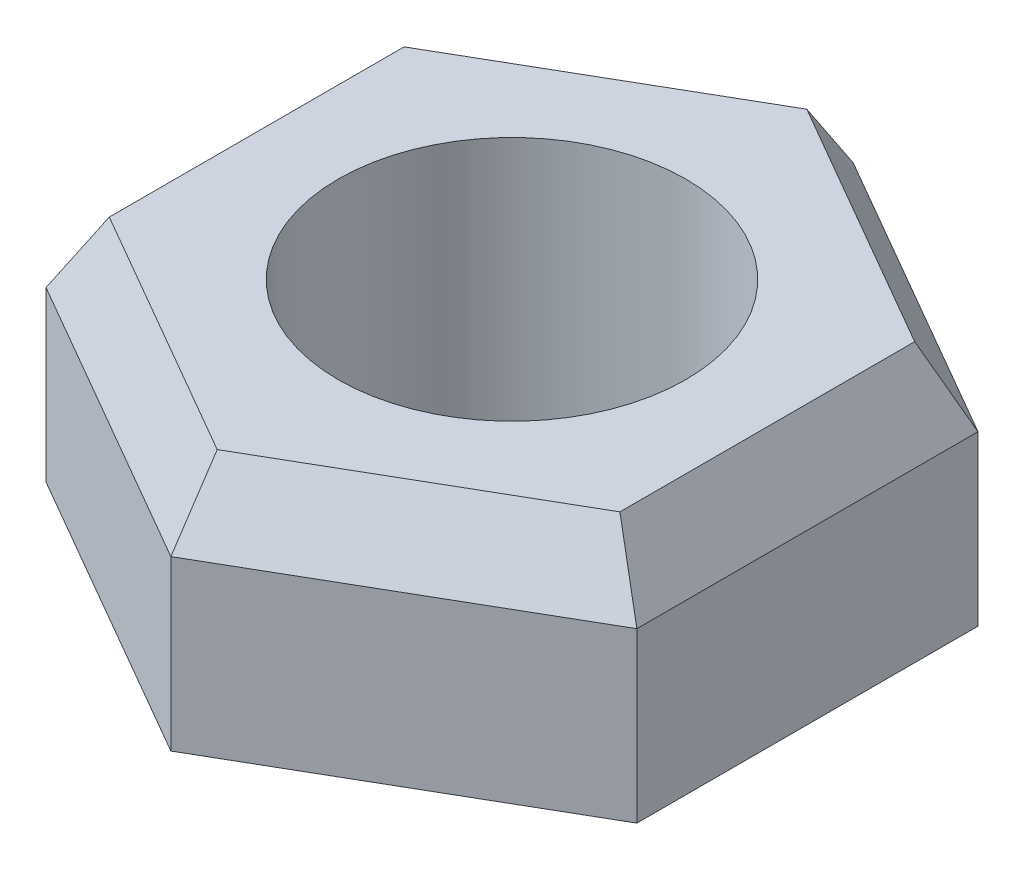
from build123d import *

# Parameters (mm, degrees)
SKETCH_1_R             = 5
EXTRUDE_1_DEPTH        = 8
CHAMFER_1_SIZE         = 2
CHAMFER_1_SIZE2        = 1.154700538
CHAMFER_1_PART_2_SIZE  = 2
CHAMFER_1_PART_2_SIZE2 = 1.154700538
CHAMFER_1_PART_3_SIZE  = 2
CHAMFER_1_PART_3_SIZE2 = 1.154700538
CHAMFER_1_PART_4_SIZE  = 2
CHAMFER_1_PART_4_SIZE2 = 1.154700538
CHAMFER_1_PART_5_SIZE  = 2
CHAMFER_1_PART_5_SIZE2 = 1.154700538
CHAMFER_1_PART_6_SIZE  = 2
CHAMFER_1_PART_6_SIZE2 = 1.154700538
CHAMFER_1_PART_7_SIZE  = 2
CHAMFER_1_PART_7_SIZE2 = 1.154700538


with BuildPart() as part:
    # Эскиз1 → Бобышка-Вытянуть1 (new body)
    with BuildSketch(Plane(origin=(0, 0, 0), x_dir=(1, 0, 0), z_dir=(0, 1, 0))):
        Polygon((8.5, -4.907477288), (8.5, 4.907477288), (0, 9.814954576), (-8.5, 4.907477288), (-8.5, -4.907477288), (0, -9.814954576), align=None)
        Circle(SKETCH_1_R, mode=Mode.SUBTRACT)
    extrude(amount=EXTRUDE_1_DEPTH)

    # Фаска1
    chamfer_1_edges = [part.edges().sort_by_distance(p)[0] for p in [
        (4.25, 8, -7.361215932),
    ]]
    chamfer_1_side = [part.faces().sort_by_distance(p)[0] for p in [
        (4.25, 4, -7.361215932),
    ]]
    chamfer(chamfer_1_edges, length=CHAMFER_1_SIZE, length2=CHAMFER_1_SIZE2, reference=chamfer_1_side[0])

    # Фаска1 part 2
    chamfer_1_part_2_edges = [part.edges().sort_by_distance(p)[0] for p in [
        (-4.25, 8, -7.361215932),
    ]]
    chamfer_1_part_2_side = [part.faces().sort_by_distance(p)[0] for p in [
        (-4.25, 4, -7.361215932),
    ]]
    chamfer(chamfer_1_part_2_edges, length=CHAMFER_1_PART_2_SIZE, length2=CHAMFER_1_PART_2_SIZE2, reference=chamfer_1_part_2_side[0])

    # Фаска1 part 3
    chamfer_1_part_3_edges = [part.edges().sort_by_distance(p)[0] for p in [
        (-8.5, 8, 0),
    ]]
    chamfer_1_part_3_side = [part.faces().sort_by_distance(p)[0] for p in [
        (-8.5, 4, 0),
    ]]
    chamfer(chamfer_1_part_3_edges, length=CHAMFER_1_PART_3_SIZE, length2=CHAMFER_1_PART_3_SIZE2, reference=chamfer_1_part_3_side[0])

    # Фаска1 part 4
    chamfer_1_part_4_edges = [part.edges().sort_by_distance(p)[0] for p in [
        (-4.25, 8, 7.361215932),
    ]]
    chamfer_1_part_4_side = [part.faces().sort_by_distance(p)[0] for p in [
        (-4.25, 4, 7.361215932),
    ]]
    chamfer(chamfer_1_part_4_edges, length=CHAMFER_1_PART_4_SIZE, length2=CHAMFER_1_PART_4_SIZE2, reference=chamfer_1_part_4_side[0])

    # Фаска1 part 5
    chamfer_1_part_5_edges = [part.edges().sort_by_distance(p)[0] for p in [
        (4.25, 8, 7.361215932),
    ]]
    chamfer_1_part_5_side = [part.faces().sort_by_distance(p)[0] for p in [
        (4.25, 4, 7.361215932),
    ]]
    chamfer(chamfer_1_part_5_edges, length=CHAMFER_1_PART_5_SIZE, length2=CHAMFER_1_PART_5_SIZE2, reference=chamfer_1_part_5_side[0])

    # Фаска1 part 6
    chamfer_1_part_6_edges = [part.edges().sort_by_distance(p)[0] for p in [
        (-4.25, 0, 7.361215932),
        (-8.5, 0, 0),
        (-4.25, 0, -7.361215932),
        (4.25, 0, -7.361215932),
        (8.5, 0, 0),
        (4.25, 0, 7.361215932),
    ]]
    chamfer_1_part_6_side = [part.faces().sort_by_distance(p)[0] for p in [
        (8.240320711, 0, 0),
    ]]
    chamfer(chamfer_1_part_6_edges, length=CHAMFER_1_PART_6_SIZE, length2=CHAMFER_1_PART_6_SIZE2, reference=chamfer_1_part_6_side[0])

    # Фаска1 part 7
    chamfer_1_part_7_edges = [part.edges().sort_by_distance(p)[0] for p in [
        (8.5, 8, 0),
    ]]
    chamfer_1_part_7_side = [part.faces().sort_by_distance(p)[0] for p in [
        (8.5, 4, 0),
    ]]
    chamfer(chamfer_1_part_7_edges, length=CHAMFER_1_PART_7_SIZE, length2=CHAMFER_1_PART_7_SIZE2, reference=chamfer_1_part_7_side[0])


solid = part.part
